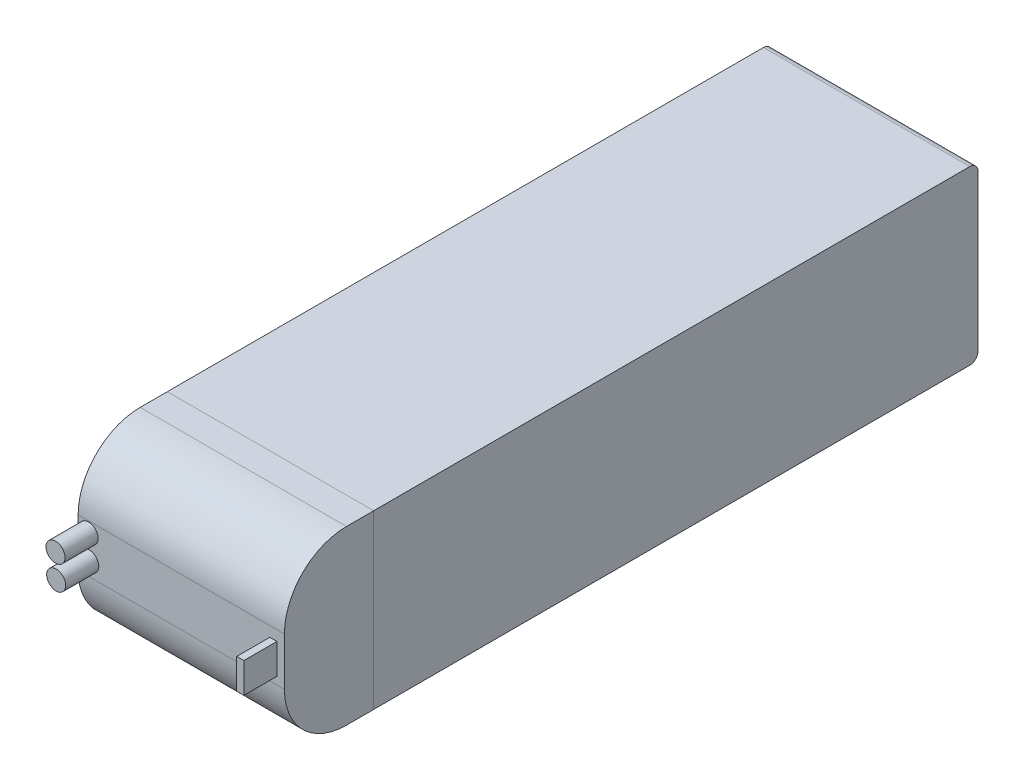
from build123d import *

# Parameters (mm, degrees)
SKETCH1_W           = 49.87
SKETCH1_H           = 146.11
BOSS_EXTRUDE1_DEPTH = 41.6
SKETCH2_W           = 49.87
SKETCH2_H           = 41.6
BOSS_EXTRUDE2_DEPTH = 21.57
FILLET2_R           = 15
SKETCH6_R           = 2.305
BOSS_EXTRUDE4_DEPTH = 8
SKETCH7_R           = 2.305
BOSS_EXTRUDE5_DEPTH = 8
SKETCH8_W           = 1.72
SKETCH8_H           = 7.3
BOSS_EXTRUDE6_DEPTH = 8
FILLET3_R           = 2


with BuildPart() as part:
    # Sketch1 → Boss-Extrude1 (new body)
    with BuildSketch(Plane(origin=(0, 0, 0), x_dir=(1, 0, 0), z_dir=(0, 1, 0))):
        Rectangle(SKETCH1_W, SKETCH1_H)
    extrude(amount=BOSS_EXTRUDE1_DEPTH)

    # Sketch2 → Boss-Extrude2 (add)
    with BuildSketch(Plane.XY.offset(73.055)):
        with Locations((0.021729079, 20.81046652)):
            Rectangle(SKETCH2_W, SKETCH2_H)
    extrude(amount=BOSS_EXTRUDE2_DEPTH)

    # Fillet2
    fillet2_edges = [part.edges().sort_by_distance(p)[0] for p in [
        (0.021729079, 0.01046652, 94.625),
        (0.021729079, 41.61046652, 94.625),
    ]]
    fillet(fillet2_edges, radius=FILLET2_R)

    # Sketch6 → Boss-Extrude4 (add)
    with BuildSketch(Plane.XY.offset(94.625)):
        with Locations((-22.382137535, 24.07655878)):
            Circle(SKETCH6_R)
    extrude(amount=BOSS_EXTRUDE4_DEPTH)

    # Sketch7 → Boss-Extrude5 (add)
    with BuildSketch(Plane.XY.offset(94.625)):
        with Locations((-22.226360129, 18.312794768)):
            Circle(SKETCH7_R)
    extrude(amount=BOSS_EXTRUDE5_DEPTH)

    # Sketch8 → Boss-Extrude6 (add)
    with BuildSketch(Plane.XY.offset(94.625)):
        with Locations((22.28703356, 20.493678449)):
            Rectangle(SKETCH8_W, SKETCH8_H)
    extrude(amount=BOSS_EXTRUDE6_DEPTH)

    # Fillet3
    fillet3_edges = [part.edges().sort_by_distance(p)[0] for p in [
        (0, 41.6, -73.055),
        (0, 0, -73.055),
    ]]
    fillet(fillet3_edges, radius=FILLET3_R)


solid = part.part
